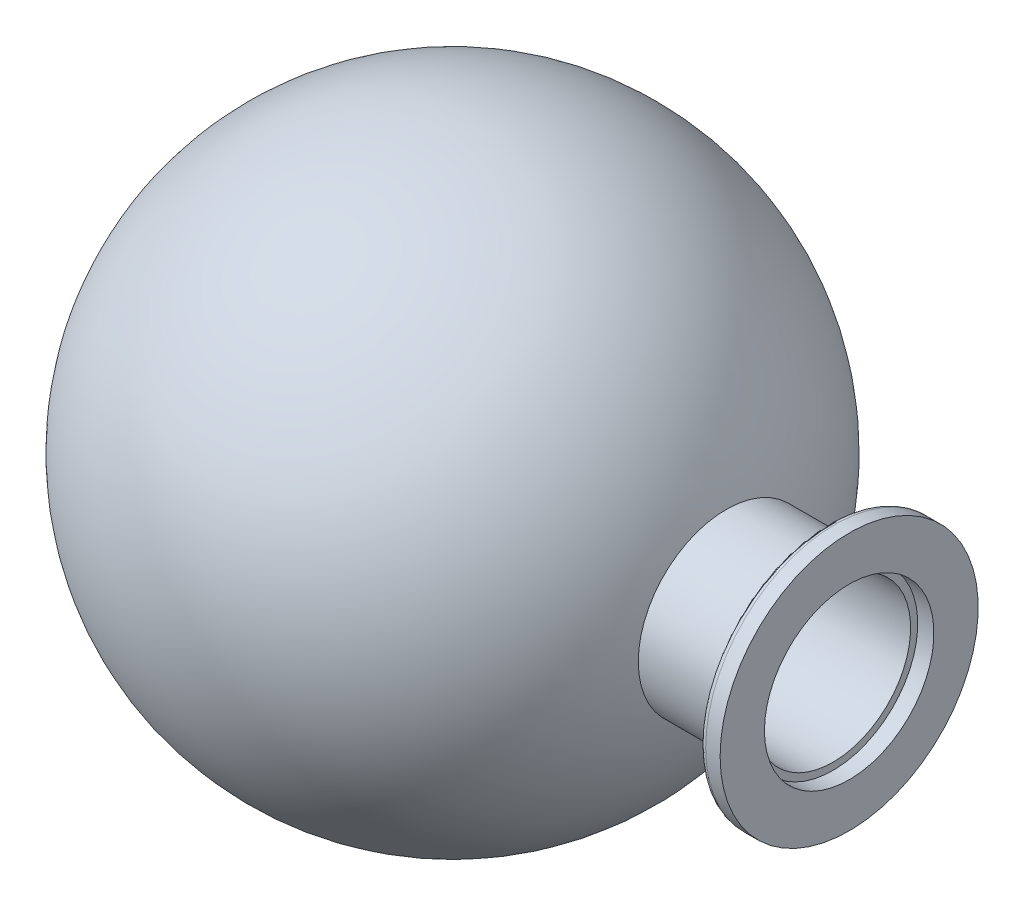
from build123d import *


with BuildPart() as part:
    # Esquisse1 → Révolution1 (revolve)
    with BuildSketch(Plane.XY, mode=Mode.PRIVATE) as r_volution1_sk:
        with BuildLine():
            Line((-42.799561914, 12), (58.818347085, 12))
            Line((58.818347085, 12), (58.818347085, 13.1))
            Line((58.818347085, 13.1), (61.318347085, 13.1))
            Line((61.318347085, 13.1), (61.318347085, 19.95))
            Line((61.318347085, 19.95), (59.085674073, 19.95))
            ThreePointArc((59.085674073, 19.95), (58.476912644, 19.74335334), (58.119748247, 19.208819045))
            Line((58.119748247, 19.208819045), (56.616869713, 13.6))
            Line((56.616869713, 13.6), (42.318347085, 13.6))
            ThreePointArc((42.318347085, 13.6), (-0.835399263, 44.442149004), (-42.799561914, 12))
        make_face()
    revolve(r_volution1_sk.sketch.rotate(Axis((-48.090955631, 0, 0), (1, 0, 0)), 90), axis=Axis((-48.090955631, 0, 0), (1, 0, 0)))  # turned: the seam where the file's is


solid = part.part
